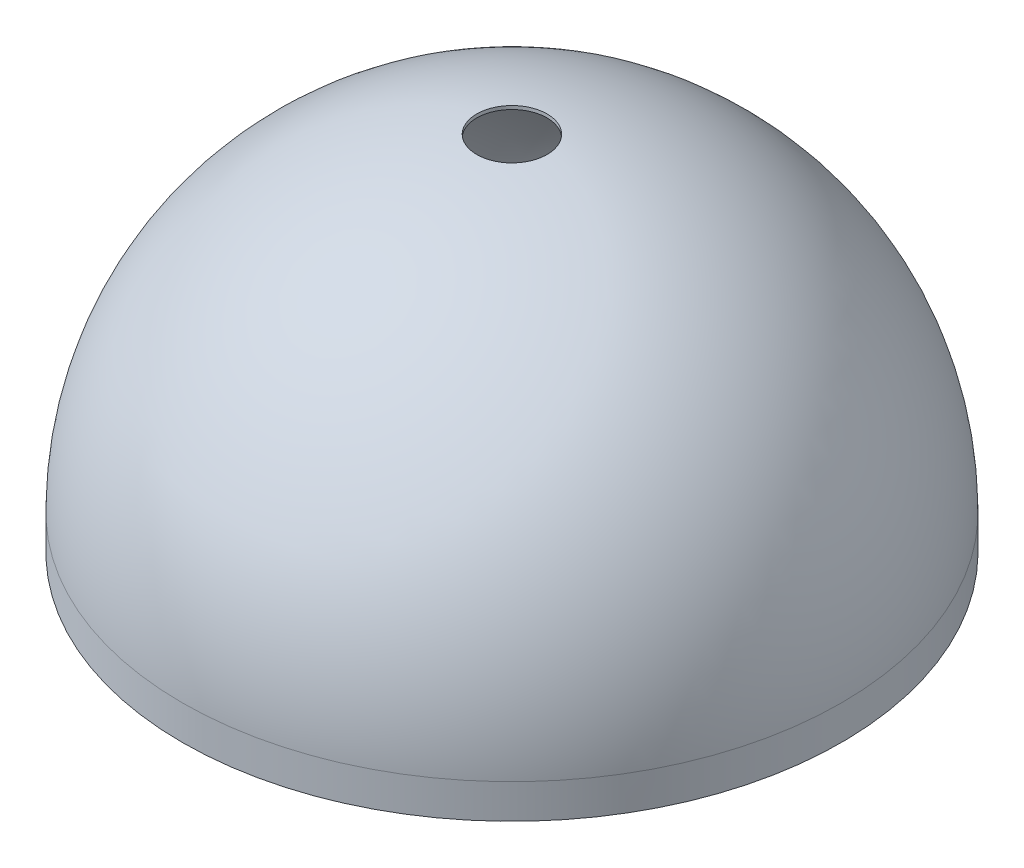
from build123d import *

# Parameters (mm, degrees)
SKETCH3_R           = 2.6035
CUT_EXTRUDE1_DEPTH  = 25.384
SKETCH4_R           = 24.384
SKETCH4_R_2         = 24.13
BOSS_EXTRUDE1_DEPTH = 2.54


with BuildPart() as part:
    # Sketch2 → Revolve1 (revolve)
    with BuildSketch(Plane(origin=(0, 0, 0), x_dir=(0, 0, -1), z_dir=(1, 0, 0))):
        with BuildLine():
            Line((24.13, 0), (24.384, 0))
            ThreePointArc((24.384, 0), (17.242091752, 17.242091752), (0, 24.384))
            Line((0, 24.384), (0, 24.13))
            ThreePointArc((0, 24.13), (17.06248663, 17.06248663), (24.13, 0))
        make_face()
    revolve(axis=Axis((0, 0, 0), (0, 1, 0)))

    # Sketch3 → Cut-Extrude1 (cut, through all)
    with BuildSketch(Plane(origin=(0, 0, 0), x_dir=(1, 0, 0), z_dir=(0, 1, 0))):
        Circle(SKETCH3_R)
    extrude(amount=CUT_EXTRUDE1_DEPTH, mode=Mode.SUBTRACT)

    # Sketch4 → Boss-Extrude1 (add)
    with BuildSketch(Plane(origin=(0, 0, 0), x_dir=(1, 0, 0), z_dir=(0, 1, 0))):
        Circle(SKETCH4_R)
        Circle(SKETCH4_R_2, mode=Mode.SUBTRACT)
    extrude(amount=-BOSS_EXTRUDE1_DEPTH)


solid = part.part
